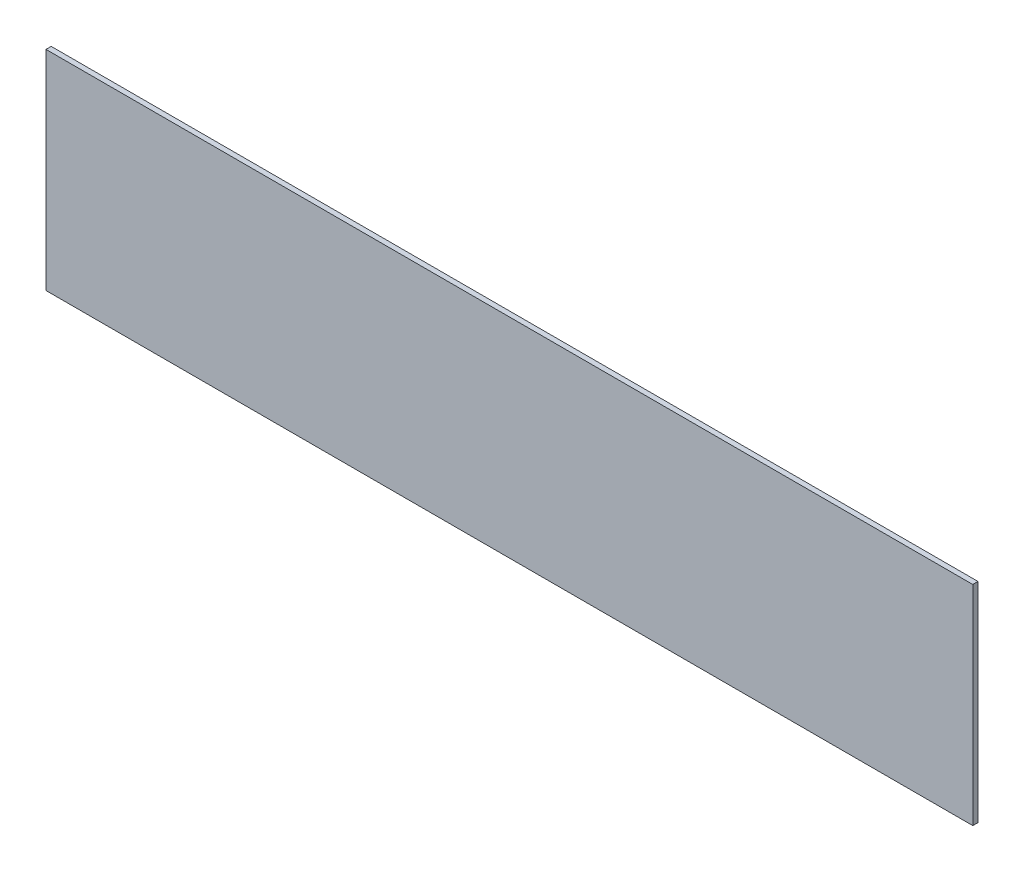
from build123d import *

# Parameters (mm, degrees)
ESBO_O1_W                = 355
ESBO_O1_H                = 80
RESSALTO_EXTRUS_O1_DEPTH = 2


with BuildPart() as part:
    # Esboço1 → Ressalto-extrusão1 (new body)
    with BuildSketch(Plane.XY):
        Rectangle(ESBO_O1_W, ESBO_O1_H)
    extrude(amount=RESSALTO_EXTRUS_O1_DEPTH)


solid = part.part
